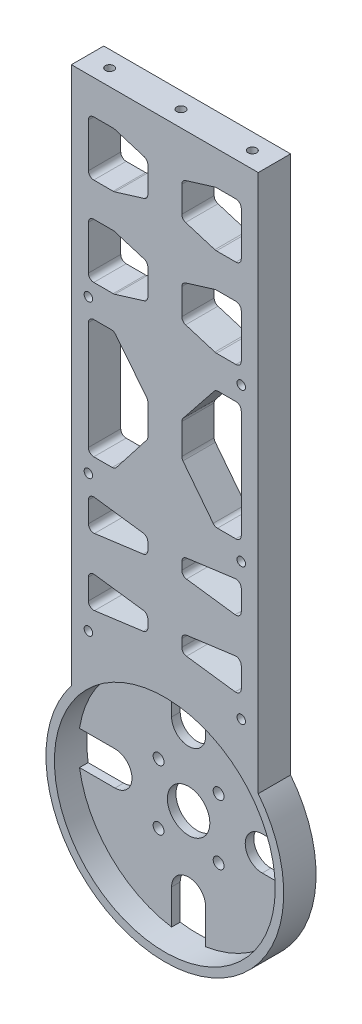
from build123d import *

# Parameters (mm, degrees)
SKETCH1_R                       = 6.25
BOSS_EXTRUDE4_DEPTH             = 9.525
SKETCH3_R                       = 32.5
CUT_EXTRUDE1_DEPTH              = 7
TAP_DRILL_FOR_M3X0_5_TAP1_D     = 2.5
TAP_DRILL_FOR_M3X0_5_TAP1_DEPTH = 7.5
TAP_DRILL_FOR_M3X0_5_TAP1_TIP   = 0.751075774
TAP_DRILL_FOR_M3X0_5_TAP2_D     = 2.5
TAP_DRILL_FOR_M3X0_5_TAP3_D     = 2.5
M3_CLEARANCE_HOLE2_D            = 3.2


with BuildPart() as part:
    # Sketch1 → Boss-Extrude4 (new body)
    with BuildSketch(Plane.XY):
        with BuildLine():
            Line((27.5, 180), (-27.5, 180))
            Line((-27.5, 180), (-27.5, 21.650635095))
            ThreePointArc((-27.5, 21.650635095), (0, -35), (27.5, 21.650635095))
            Line((27.5, 21.650635095), (27.5, 180))
        make_face()
        with BuildLine():
            Line((-22.5, 45.784893964), (-22.5, 51.834479566))
            ThreePointArc((-22.5, 51.834479566), (-21.958050648, 53.029042285), (-20.702229806, 53.407992418))
            Line((-20.702229806, 53.407992418), (-6.377229806, 51.493727447))
            ThreePointArc((-6.377229806, 51.493727447), (-5.39293728, 50.965765243), (-5, 49.920214595))
            Line((-5, 49.920214595), (-5, 47.699158934))
            ThreePointArc((-5, 47.699158934), (-5.39293728, 46.653608286), (-6.377229806, 46.125646082))
            Line((-6.377229806, 46.125646082), (-20.702229806, 44.211381112))
            ThreePointArc((-20.702229806, 44.211381112), (-21.958050648, 44.590331244), (-22.5, 45.784893964))
        make_face(mode=Mode.SUBTRACT)
        with BuildLine():
            Line((-22.5, 65.461981152), (-22.5, 71.511566754))
            ThreePointArc((-22.5, 71.511566754), (-21.958050648, 72.706129474), (-20.702229806, 73.085079606))
            Line((-20.702229806, 73.085079606), (-6.377229806, 71.170814635))
            ThreePointArc((-6.377229806, 71.170814635), (-5.39293728, 70.642852432), (-5, 69.597301783))
            Line((-5, 69.597301783), (-5, 67.376246123))
            ThreePointArc((-5, 67.376246123), (-5.39293728, 66.330695474), (-6.377229806, 65.802733271))
            Line((-6.377229806, 65.802733271), (-20.702229806, 63.8884683))
            ThreePointArc((-20.702229806, 63.8884683), (-21.958050648, 64.267418432), (-22.5, 65.461981152))
        make_face(mode=Mode.SUBTRACT)
        with BuildLine():
            ThreePointArc((-5, 32.113081447), (0, 32.5), (5, 32.113081447))
            ThreePointArc((5, 32.113081447), (22.980970389, 22.980970389), (32.113081447, 5))
            ThreePointArc((32.113081447, 5), (32.403125984, 2.507474126), (32.5, 0))
            ThreePointArc((32.5, 0), (32.403125984, -2.507474126), (32.113081447, -5))
            ThreePointArc((32.113081447, -5), (22.980970389, -22.980970389), (5, -32.113081447))
            ThreePointArc((5, -32.113081447), (0, -32.5), (-5, -32.113081447))
            ThreePointArc((-5, -32.113081447), (-22.980970389, -22.980970389), (-32.113081447, -5))
            ThreePointArc((-32.113081447, -5), (-32.5, 0), (-32.113081447, 5))
            ThreePointArc((-32.113081447, 5), (-22.980970389, 22.980970389), (-5, 32.113081447))
        make_face(mode=Mode.SUBTRACT)
        with BuildLine():
            Line((20.702229806, 44.211381112), (6.377229806, 46.125646082))
            ThreePointArc((6.377229806, 46.125646082), (5.39293728, 46.653608286), (5, 47.699158934))
            Line((5, 47.699158934), (5, 49.920214595))
            ThreePointArc((5, 49.920214595), (5.39293728, 50.965765243), (6.377229806, 51.493727447))
            Line((6.377229806, 51.493727447), (20.702229806, 53.407992418))
            ThreePointArc((20.702229806, 53.407992418), (21.958050648, 53.029042285), (22.5, 51.834479566))
            Line((22.5, 51.834479566), (22.5, 45.784893964))
            ThreePointArc((22.5, 45.784893964), (21.958050648, 44.590331244), (20.702229806, 44.211381112))
        make_face(mode=Mode.SUBTRACT)
        with BuildLine():
            ThreePointArc((20.702229806, 73.085079606), (21.958050648, 72.706129474), (22.5, 71.511566754))
            Line((22.5, 71.511566754), (22.5, 65.461981152))
            ThreePointArc((22.5, 65.461981152), (21.958050648, 64.267418432), (20.702229806, 63.8884683))
            Line((20.702229806, 63.8884683), (6.377229806, 65.802733271))
            ThreePointArc((6.377229806, 65.802733271), (5.39293728, 66.330695474), (5, 67.376246123))
            Line((5, 67.376246123), (5, 69.597301783))
            ThreePointArc((5, 69.597301783), (5.39293728, 70.642852432), (6.377229806, 71.170814635))
            Line((6.377229806, 71.170814635), (20.702229806, 73.085079606))
        make_face(mode=Mode.SUBTRACT)
        with BuildLine():
            ThreePointArc((-15.726133743, 118.325317547), (-15.03709411, 118.167985592), (-14.484631426, 117.72717504))
            Line((-14.484631426, 117.72717504), (-5.345997684, 106.259495212))
            ThreePointArc((-5.345997684, 106.259495212), (-5.088993881, 105.794194645), (-5, 105.270137719))
            Line((-5, 105.270137719), (-5, 96.370001101))
            ThreePointArc((-5, 96.370001101), (-5.085926297, 95.854799526), (-5.334403355, 95.395370377))
            Line((-5.334403355, 95.395370377), (-14.245546119, 83.938186823))
            ThreePointArc((-14.245546119, 83.938186823), (-14.801172343, 83.486742072), (-15.498642764, 83.325317547))
            Line((-15.498642764, 83.325317547), (-20.9125, 83.325317547))
            ThreePointArc((-20.9125, 83.325317547), (-22.035032015, 83.790285532), (-22.5, 84.912817547))
            Line((-22.5, 84.912817547), (-22.5, 116.737817547))
            ThreePointArc((-22.5, 116.737817547), (-22.035032015, 117.860349562), (-20.9125, 118.325317547))
            Line((-20.9125, 118.325317547), (-15.726133743, 118.325317547))
        make_face(mode=Mode.SUBTRACT)
        with BuildLine():
            ThreePointArc((-22.5, 142.297817547), (-22.035032015, 143.420349562), (-20.9125, 143.885317547))
            Line((-20.9125, 143.885317547), (-15.198883954, 143.885317547))
            ThreePointArc((-15.198883954, 143.885317547), (-14.963910291, 143.867831441), (-14.734113036, 143.815758338))
            Line((-14.734113036, 143.815758338), (-6.122729082, 141.179080512))
            ThreePointArc((-6.122729082, 141.179080512), (-5.311181058, 140.605155721), (-5, 139.661139721))
            Line((-5, 139.661139721), (-5, 132.009495374))
            ThreePointArc((-5, 132.009495374), (-5.311181058, 131.065479373), (-6.122729082, 130.491554583))
            Line((-6.122729082, 130.491554583), (-14.734113036, 127.854876757))
            ThreePointArc((-14.734113036, 127.854876757), (-14.963910291, 127.802803653), (-15.198883954, 127.785317547))
            Line((-15.198883954, 127.785317547), (-20.9125, 127.785317547))
            ThreePointArc((-20.9125, 127.785317547), (-22.035032015, 128.250285532), (-22.5, 129.372817547))
            Line((-22.5, 129.372817547), (-22.5, 142.297817547))
        make_face(mode=Mode.SUBTRACT)
        with BuildLine():
            Line((-22.5, 155.472817547), (-22.5, 168.397817547))
            ThreePointArc((-22.5, 168.397817547), (-22.035032015, 169.520349562), (-20.9125, 169.985317547))
            Line((-20.9125, 169.985317547), (-15.198883954, 169.985317547))
            ThreePointArc((-15.198883954, 169.985317547), (-14.963910291, 169.967831441), (-14.734113036, 169.915758338))
            Line((-14.734113036, 169.915758338), (-6.122729082, 167.279080512))
            ThreePointArc((-6.122729082, 167.279080512), (-5.311181058, 166.705155721), (-5, 165.761139721))
            Line((-5, 165.761139721), (-5, 158.109495374))
            ThreePointArc((-5, 158.109495374), (-5.311181058, 157.165479373), (-6.122729082, 156.591554583))
            Line((-6.122729082, 156.591554583), (-14.734113036, 153.954876757))
            ThreePointArc((-14.734113036, 153.954876757), (-14.963910291, 153.902803653), (-15.198883954, 153.885317547))
            Line((-15.198883954, 153.885317547), (-20.9125, 153.885317547))
            ThreePointArc((-20.9125, 153.885317547), (-22.035032015, 154.350285532), (-22.5, 155.472817547))
        make_face(mode=Mode.SUBTRACT)
        with BuildLine():
            ThreePointArc((20.9125, 118.325317547), (22.035032015, 117.860349562), (22.5, 116.737817547))
            Line((22.5, 116.737817547), (22.5, 84.912817547))
            ThreePointArc((22.5, 84.912817547), (22.035032015, 83.790285532), (20.9125, 83.325317547))
            Line((20.9125, 83.325317547), (15.498642764, 83.325317547))
            ThreePointArc((15.498642764, 83.325317547), (14.801172343, 83.486742072), (14.245546119, 83.938186823))
            Line((14.245546119, 83.938186823), (5.334403355, 95.395370377))
            ThreePointArc((5.334403355, 95.395370377), (5.085926297, 95.854799526), (5, 96.370001101))
            Line((5, 96.370001101), (5, 105.270137719))
            ThreePointArc((5, 105.270137719), (5.088993881, 105.794194645), (5.345997684, 106.259495212))
            Line((5.345997684, 106.259495212), (14.484631426, 117.72717504))
            ThreePointArc((14.484631426, 117.72717504), (15.03709411, 118.167985592), (15.726133743, 118.325317547))
            Line((15.726133743, 118.325317547), (20.9125, 118.325317547))
        make_face(mode=Mode.SUBTRACT)
        with BuildLine():
            Line((14.734113036, 127.854876757), (6.122729082, 130.491554583))
            ThreePointArc((6.122729082, 130.491554583), (5.311181058, 131.065479373), (5, 132.009495374))
            Line((5, 132.009495374), (5, 139.661139721))
            ThreePointArc((5, 139.661139721), (5.311181058, 140.605155721), (6.122729082, 141.179080512))
            Line((6.122729082, 141.179080512), (14.734113036, 143.815758338))
            ThreePointArc((14.734113036, 143.815758338), (14.963910291, 143.867831441), (15.198883954, 143.885317547))
            Line((15.198883954, 143.885317547), (20.9125, 143.885317547))
            ThreePointArc((20.9125, 143.885317547), (22.035032015, 143.420349562), (22.5, 142.297817547))
            Line((22.5, 142.297817547), (22.5, 129.372817547))
            ThreePointArc((22.5, 129.372817547), (22.035032015, 128.250285532), (20.9125, 127.785317547))
            Line((20.9125, 127.785317547), (15.198883954, 127.785317547))
            ThreePointArc((15.198883954, 127.785317547), (14.963910291, 127.802803653), (14.734113036, 127.854876757))
        make_face(mode=Mode.SUBTRACT)
        with BuildLine():
            Line((14.734113036, 153.954876757), (6.122729082, 156.591554583))
            ThreePointArc((6.122729082, 156.591554583), (5.311181058, 157.165479373), (5, 158.109495374))
            Line((5, 158.109495374), (5, 165.761139721))
            ThreePointArc((5, 165.761139721), (5.311181058, 166.705155721), (6.122729082, 167.279080512))
            Line((6.122729082, 167.279080512), (14.734113036, 169.915758338))
            ThreePointArc((14.734113036, 169.915758338), (14.963910291, 169.967831441), (15.198883954, 169.985317547))
            Line((15.198883954, 169.985317547), (20.9125, 169.985317547))
            ThreePointArc((20.9125, 169.985317547), (22.035032015, 169.520349562), (22.5, 168.397817547))
            Line((22.5, 168.397817547), (22.5, 155.472817547))
            ThreePointArc((22.5, 155.472817547), (22.035032015, 154.350285532), (20.9125, 153.885317547))
            Line((20.9125, 153.885317547), (15.198883954, 153.885317547))
            ThreePointArc((15.198883954, 153.885317547), (14.963910291, 153.902803653), (14.734113036, 153.954876757))
        make_face(mode=Mode.SUBTRACT)
        with BuildLine():
            Line((5, 32.113081447), (5, 21.466517846))
            ThreePointArc((5, 21.466517846), (0, 16.466517846), (-5, 21.466517846))
            Line((-5, 21.466517846), (-5, 32.113081447))
            ThreePointArc((-5, 32.113081447), (-22.980970389, 22.980970389), (-32.113081447, 5))
            Line((-32.113081447, 5), (-21.67, 5))
            ThreePointArc((-21.67, 5), (-16.67, 0), (-21.67, -5))
            Line((-21.67, -5), (-32.113081447, -5))
            ThreePointArc((-32.113081447, -5), (-22.980970389, -22.980970389), (-5, -32.113081447))
            Line((-5, -32.113081447), (-5, -21.872218084))
            ThreePointArc((-5, -21.872218084), (0, -16.872218084), (5, -21.872218084))
            Line((5, -21.872218084), (5, -32.113081447))
            ThreePointArc((5, -32.113081447), (22.980970389, -22.980970389), (32.113081447, -5))
            Line((32.113081447, -5), (21.67, -5))
            ThreePointArc((21.67, -5), (16.67, 0), (21.67, 5))
            Line((21.67, 5), (32.113081447, 5))
            ThreePointArc((32.113081447, 5), (22.980970389, 22.980970389), (5, 32.113081447))
        make_face()
        Circle(SKETCH1_R, mode=Mode.SUBTRACT)
    extrude(amount=BOSS_EXTRUDE4_DEPTH)

    # Sketch3 → Cut-Extrude1 (cut)
    with BuildSketch(Plane.XY.offset(9.525)):
        Circle(SKETCH3_R)
    extrude(amount=-CUT_EXTRUDE1_DEPTH, mode=Mode.SUBTRACT)

    # Tap Drill for M3x0.5 Tap1
    with Locations(Plane(origin=(0, 180, 0), x_dir=(1, 0, 0), z_dir=(0, 1, 0))):
        with Locations((-21, -4.7625), (0, 16.898932686), (21, -4.7625), (0, -4.7625)):
            Hole(TAP_DRILL_FOR_M3X0_5_TAP1_D / 2, depth=TAP_DRILL_FOR_M3X0_5_TAP1_DEPTH)
            with Locations((0, 0, -(TAP_DRILL_FOR_M3X0_5_TAP1_DEPTH + TAP_DRILL_FOR_M3X0_5_TAP1_TIP / 2))):  # 118° drill point
                Cone(0, TAP_DRILL_FOR_M3X0_5_TAP1_D / 2, TAP_DRILL_FOR_M3X0_5_TAP1_TIP, mode=Mode.SUBTRACT)

    # Tap Drill for M3x0.5 Tap2 (through all)
    with Locations(Plane.XY.offset(9.525)):
        with Locations((-22.5, 123.325317547), (22.5, 123.325317547), (22.5, 78.325317547), (-22.5, 78.325317547)):
            Hole(TAP_DRILL_FOR_M3X0_5_TAP2_D / 2)

    # Tap Drill for M3x0.5 Tap3 (through all)
    with Locations(Plane.XY.offset(9.525)):
        with Locations((-22.5, 38.13933941), (22.5, 38.13933941)):
            Hole(TAP_DRILL_FOR_M3X0_5_TAP3_D / 2)

    # M3 Clearance Hole2 (through all)
    with Locations(Plane.XY.offset(9.525)):
        with Locations((-8.838834765, 8.838834765), (8.838834765, 8.838834765), (8.838834765, -8.838834765), (-8.838834765, -8.838834765)):
            Hole(M3_CLEARANCE_HOLE2_D / 2)


solid = part.part
